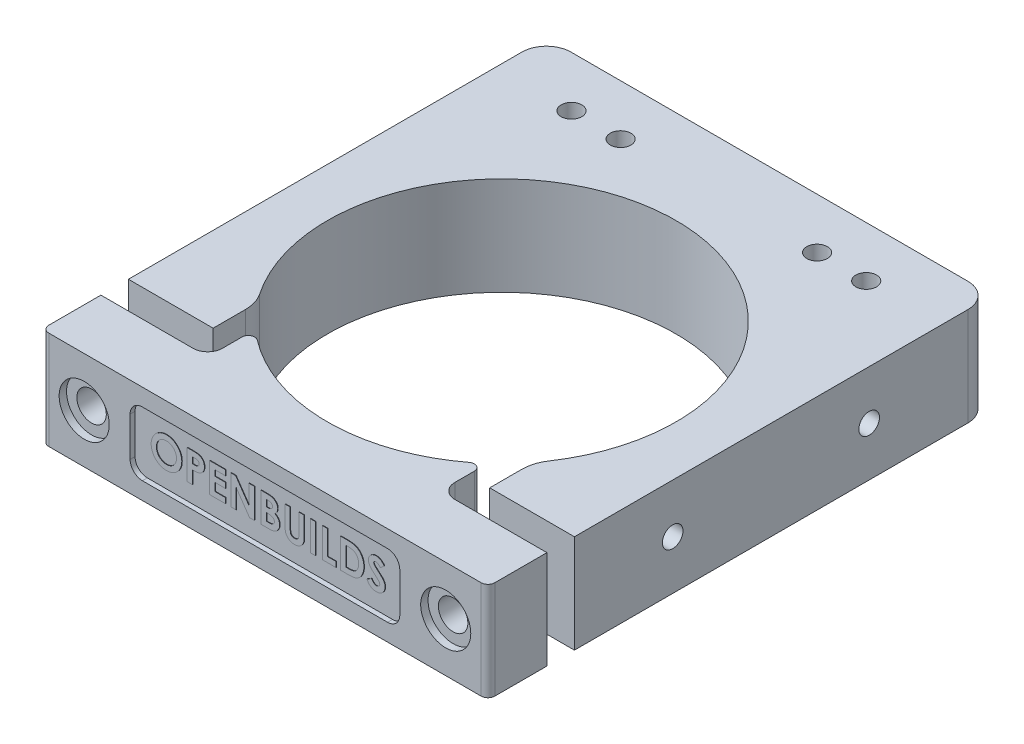
from build123d import *

# Parameters (mm, degrees)
BOSS_EXTRUDE1_DEPTH            = 20
BOSS_EXTRUDE1_2_DEPTH          = 20
SKETCH2_W                      = 2.1
SKETCH2_H                      = 20
M5X0_8_TAPPED_HOLE1_AT_2_COUNT = 2
M5X0_8_TAPPED_HOLE1_AT_2_PITCH = 10
M5X0_8_TAPPED_HOLE1_AT_3_COUNT = 2
M5X0_8_TAPPED_HOLE1_AT_3_PITCH = 50
M5X0_8_TAPPED_HOLE1_AT_4_COUNT = 2
M5X0_8_TAPPED_HOLE1_AT_4_PITCH = 60
HOLE1_AT_2_COUNT               = 2
HOLE1_AT_2_PITCH               = 73.6
M5X0_8_TAPPED_HOLE2_AT_2_COUNT = 2
M5X0_8_TAPPED_HOLE2_AT_2_PITCH = 73.6
M5X0_8_TAPPED_HOLE3_AT_2_COUNT = 2
M5X0_8_TAPPED_HOLE3_AT_2_PITCH = 40
M5X0_8_TAPPED_HOLE4_AT_2_COUNT = 2
M5X0_8_TAPPED_HOLE4_AT_2_PITCH = 20
M5X0_8_TAPPED_HOLE4_AT_3_COUNT = 2
M5X0_8_TAPPED_HOLE4_AT_3_PITCH = 60
M5X0_8_TAPPED_HOLE4_AT_4_COUNT = 2
M5X0_8_TAPPED_HOLE4_AT_4_PITCH = 40
CUT_EXTRUDE1_DEPTH             = 1
SKETCH13_W                     = 1.076923077
SKETCH13_H                     = 6
BOSS_EXTRUDE2_DEPTH            = 0.1


with BuildPart() as part:
    # Sketch1 → Boss-Extrude1 (new body)
    with BuildSketch(Plane(origin=(0, 0, 0), x_dir=(1, 0, 0), z_dir=(0, 1, 0))):
        with BuildLine():
            Line((-45.4, -30.6), (-28.15, -30.6))
            Line((-28.15, -30.6), (-28.15, -24.043242294))
            ThreePointArc((-28.15, -24.043242294), (-28.477651207, -21.850660986), (-29.431976744, -19.849653522))
            ThreePointArc((-29.431976744, -19.849653522), (0, 35.5), (29.431976744, -19.849653522))
            ThreePointArc((29.431976744, -19.849653522), (28.477651207, -21.850660986), (28.15, -24.043242294))
            Line((28.15, -24.043242294), (28.15, -30.6))
            Line((28.15, -30.6), (45.4, -30.6))
            Line((45.4, -30.6), (45.4, 49.5))
            ThreePointArc((45.4, 49.5), (43.935533906, 53.035533906), (40.4, 54.5))
            Line((40.4, 54.5), (-40.4, 54.5))
            ThreePointArc((-40.4, 54.5), (-43.935533906, 53.035533906), (-45.4, 49.5))
            Line((-45.4, 49.5), (-45.4, -30.6))
        make_face()
    extrude(amount=BOSS_EXTRUDE1_DEPTH)

    # Sketch2 → M5x0.8 Tapped Hole1 (revolve, cut)
    with BuildSketch(Plane(origin=(-30, 20, -44.2), x_dir=(0, 0, 1), z_dir=(1, 0, 0))):
        with Locations((1.05, 10)):
            Rectangle(SKETCH2_W, SKETCH2_H)
    m5x0_8_tapped_hole1 = revolve(axis=Axis((-30, 26.35, -44.2), (0, -1, 0)), mode=Mode.SUBTRACT)

    # M5x0.8 Tapped Hole1 at 2: M5x0.8 Tapped Hole1 ×2
    with Locations(*[(i * M5X0_8_TAPPED_HOLE1_AT_2_PITCH, 0, 0) for i in range(1, M5X0_8_TAPPED_HOLE1_AT_2_COUNT)]):
        add(m5x0_8_tapped_hole1, mode=Mode.SUBTRACT)

    # M5x0.8 Tapped Hole1 at 3: M5x0.8 Tapped Hole1 ×2
    with Locations(*[(i * M5X0_8_TAPPED_HOLE1_AT_3_PITCH, 0, 0) for i in range(1, M5X0_8_TAPPED_HOLE1_AT_3_COUNT)]):
        add(m5x0_8_tapped_hole1, mode=Mode.SUBTRACT)

    # M5x0.8 Tapped Hole1 at 4: M5x0.8 Tapped Hole1 ×2
    with Locations(*[(i * M5X0_8_TAPPED_HOLE1_AT_4_PITCH, 0, 0) for i in range(1, M5X0_8_TAPPED_HOLE1_AT_4_COUNT)]):
        add(m5x0_8_tapped_hole1, mode=Mode.SUBTRACT)

    # Sketch6 → M5x0.8 Tapped Hole2 (revolve, cut)
    with BuildSketch(Plane(origin=(36.8, 10, 30.6), x_dir=(0, -1, 0), z_dir=(1, 0, 0))):
        Polygon((0, 0), (0, 14.2618073), (2.1, 13), (2.1, 0), align=None)
    m5x0_8_tapped_hole2 = revolve(axis=Axis((36.8, 10, 36.95), (0, 0, -1)), mode=Mode.SUBTRACT)

    # M5x0.8 Tapped Hole2 at 2: M5x0.8 Tapped Hole2 ×2
    with Locations(*[(-i * M5X0_8_TAPPED_HOLE2_AT_2_PITCH, 0, 0) for i in range(1, M5X0_8_TAPPED_HOLE2_AT_2_COUNT)]):
        add(m5x0_8_tapped_hole2, mode=Mode.SUBTRACT)

    # Sketch8 → M5x0.8 Tapped Hole3 (revolve, cut)
    with BuildSketch(Plane(origin=(45.4, 10, 10.6), x_dir=(0, 0, -1), z_dir=(0, 1, 0))):
        Polygon((0, 0), (0, 10.2618073), (2.1, 9), (2.1, 0), align=None)
    m5x0_8_tapped_hole3 = revolve(axis=Axis((51.75, 10, 10.6), (-1, 0, 0)), mode=Mode.SUBTRACT)

    # M5x0.8 Tapped Hole3 at 2: M5x0.8 Tapped Hole3 ×2
    with Locations(*[(0, 0, -i * M5X0_8_TAPPED_HOLE3_AT_2_PITCH) for i in range(1, M5X0_8_TAPPED_HOLE3_AT_2_COUNT)]):
        add(m5x0_8_tapped_hole3, mode=Mode.SUBTRACT)

    # Mirror1: M5x0.8 Tapped Hole3 across plane
    add(m5x0_8_tapped_hole3.mirror(Plane(origin=(0, 0, 0), x_dir=(0, 0, 1), z_dir=(1, 0, 0))), mode=Mode.SUBTRACT)

    # Mirror1 copy 1 sketch → Mirror1 copy 1 (revolve, cut)
    with BuildSketch(Plane(origin=(-45.4, 10, -29.4), x_dir=(0, 0, -1), z_dir=(0, 1, 0))):
        Polygon((0, 0), (0, -10.2618073), (2.1, -9), (2.1, 0), align=None)
    revolve(axis=Axis((-51.75, 10, -29.4), (-1, 0, 0)), mode=Mode.SUBTRACT)

    # Sketch10 → M5x0.8 Tapped Hole4 (revolve, cut)
    with BuildSketch(Plane(origin=(30, 10, -54.5), x_dir=(0, 1, 0), z_dir=(1, 0, 0))):
        Polygon((0, 0), (0, 8.2618073), (2.1, 7), (2.1, 0), align=None)
    m5x0_8_tapped_hole4 = revolve(axis=Axis((30, 10, -60.85), (0, 0, 1)), mode=Mode.SUBTRACT)

    # M5x0.8 Tapped Hole4 at 2: M5x0.8 Tapped Hole4 ×2
    with Locations(*[(-i * M5X0_8_TAPPED_HOLE4_AT_2_PITCH, 0, 0) for i in range(1, M5X0_8_TAPPED_HOLE4_AT_2_COUNT)]):
        add(m5x0_8_tapped_hole4, mode=Mode.SUBTRACT)

    # M5x0.8 Tapped Hole4 at 3: M5x0.8 Tapped Hole4 ×2
    with Locations(*[(-i * M5X0_8_TAPPED_HOLE4_AT_3_PITCH, 0, 0) for i in range(1, M5X0_8_TAPPED_HOLE4_AT_3_COUNT)]):
        add(m5x0_8_tapped_hole4, mode=Mode.SUBTRACT)

    # M5x0.8 Tapped Hole4 at 4: M5x0.8 Tapped Hole4 ×2
    with Locations(*[(-i * M5X0_8_TAPPED_HOLE4_AT_4_PITCH, 0, 0) for i in range(1, M5X0_8_TAPPED_HOLE4_AT_4_COUNT)]):
        add(m5x0_8_tapped_hole4, mode=Mode.SUBTRACT)


with BuildPart() as body_2:
    # Sketch1 → Boss-Extrude1 2 (new body)
    with BuildSketch(Plane(origin=(0, 0, 0), x_dir=(1, 0, 0), z_dir=(0, 1, 0))):
        with BuildLine():
            Line((-23.65, -29.235551987), (-23.65, -33.2))
            ThreePointArc((-23.65, -33.2), (-24.528679656, -35.321320344), (-26.65, -36.2))
            Line((-26.65, -36.2), (-45.4, -36.2))
            Line((-45.4, -36.2), (-45.4, -46.8))
            ThreePointArc((-45.4, -46.8), (-44.989949494, -47.789949494), (-44, -48.2))
            Line((-44, -48.2), (44, -48.2))
            ThreePointArc((44, -48.2), (44.989949494, -47.789949494), (45.4, -46.8))
            Line((45.4, -46.8), (45.4, -36.2))
            Line((45.4, -36.2), (26.65, -36.2))
            ThreePointArc((26.65, -36.2), (24.528679656, -35.321320344), (23.65, -33.2))
            Line((23.65, -33.2), (23.65, -29.235551987))
            ThreePointArc((23.65, -29.235551987), (22.926021069, -28.070133724), (21.560461957, -28.202774336))
            ThreePointArc((21.560461957, -28.202774336), (0, -35.5), (-21.560461957, -28.202774336))
            ThreePointArc((-21.560461957, -28.202774336), (-22.926021069, -28.070133724), (-23.65, -29.235551987))
        make_face()
    extrude(amount=BOSS_EXTRUDE1_2_DEPTH)

    # Sketch4 → Hole1 (revolve, cut)
    with BuildSketch(Plane(origin=(36.8, 10, 48.2), x_dir=(0, -1, 0), z_dir=(1, 0, 0))):
        Polygon((0, 0), (0, 12), (3, 12), (3, 1.5), (5.1, 1.5), (5.1, 0), align=None)
    hole1 = revolve(axis=Axis((36.8, 10, -61.8), (0, 0, 1)), mode=Mode.SUBTRACT)

    # Hole1 at 2: Hole1 ×2
    with Locations(*[(-i * HOLE1_AT_2_PITCH, 0, 0) for i in range(1, HOLE1_AT_2_COUNT)]):
        add(hole1, mode=Mode.SUBTRACT)

    # Sketch12 → Cut-Extrude1 (cut)
    with BuildSketch(Plane.XY.offset(48.2)):
        with BuildLine():
            Line((-24.95, 16.5), (24.95, 16.5))
            ThreePointArc((24.95, 16.5), (26.717766953, 15.767766953), (27.45, 14))
            Line((27.45, 14), (27.45, 6))
            ThreePointArc((27.45, 6), (26.717766953, 4.232233047), (24.95, 3.5))
            Line((24.95, 3.5), (-24.95, 3.5))
            ThreePointArc((-24.95, 3.5), (-26.717766953, 4.232233047), (-27.45, 6))
            Line((-27.45, 6), (-27.45, 14))
            ThreePointArc((-27.45, 14), (-26.717766953, 15.767766953), (-24.95, 16.5))
        make_face()
    extrude(amount=-CUT_EXTRUDE1_DEPTH, mode=Mode.SUBTRACT)

    # Sketch13 → Boss-Extrude2 (add)
    with BuildSketch(Plane.XY.offset(47.2)):
        with BuildLine():
            add(Edge.make_bspline(
                [(-20.937980769, 13.153846154), (-20.833663416, 13.151145191), (-20.627717333, 13.145812878), (-20.324844963, 13.101363888), (-20.032971434, 13.028940632), (-19.75222873, 12.928267067), (-19.483319798, 12.796616443), (-19.225296106, 12.63772114), (-18.979081884, 12.448582105), (-18.747200137, 12.233611639), (-18.532899583, 11.999840645), (-18.347208027, 11.748144608), (-18.18885708, 11.485045226), (-18.057615392, 11.209837517), (-17.957650418, 10.920615535), (-17.887500861, 10.618853931), (-17.842433246, 10.304638552), (-17.837249777, 10.090700708), (-17.834615385, 9.981971154)],
                knots=[0, 0, 0, 0, 0.000312833, 0.000617603, 0.000916108, 0.001213799, 0.001510526, 0.001812733, 0.0021214, 0.002440363, 0.002760287, 0.00307135, 0.003377038, 0.003680266, 0.003984355, 0.00429309, 0.004608572, 0.004934612, 0.004934612, 0.004934612, 0.004934612], degree=3))
            add(Edge.make_bspline(
                [(-17.834615385, 9.981971154), (-17.837420899, 9.874466731), (-17.842949255, 9.662625816), (-17.885661004, 9.351306056), (-17.956991888, 9.052776947), (-18.055261377, 8.766362762), (-18.184122838, 8.493450793), (-18.339385768, 8.232298534), (-18.525147263, 7.985329542), (-18.734631871, 7.752676349), (-18.965256244, 7.541493654), (-19.209524067, 7.355389269), (-19.466307461, 7.197691436), (-19.735230577, 7.068472389), (-20.016870108, 6.968190245), (-20.31053037, 6.897433906), (-20.616193192, 6.85443385), (-20.824058733, 6.848941605), (-20.929567308, 6.846153846)],
                knots=[0, 0, 0, 0, 0.000322438, 0.000635375, 0.000940602, 0.001242026, 0.001542054, 0.001844445, 0.002151897, 0.002467619, 0.002782372, 0.003088626, 0.003387526, 0.003684812, 0.003982098, 0.004282651, 0.004589633, 0.004906068, 0.004906068, 0.004906068, 0.004906068], degree=3))
            add(Edge.make_bspline(
                [(-20.929567308, 6.846153846), (-21.039916625, 6.848654603), (-21.256737951, 6.853568248), (-21.574056932, 6.900294773), (-21.878075934, 6.970681242), (-22.166241023, 7.07572927), (-22.441486914, 7.207048139), (-22.701791295, 7.3687752), (-22.947066685, 7.560643185), (-23.175906146, 7.777738284), (-23.383235252, 8.015287939), (-23.566243856, 8.266238084), (-23.720615673, 8.528671681), (-23.846356351, 8.802711553), (-23.945485251, 9.08665461), (-24.015409426, 9.382230147), (-24.056715306, 9.688729266), (-24.062468975, 9.896909595), (-24.065384615, 10.002403846)],
                knots=[0, 0, 0, 0, 0.000330843, 0.000650062, 0.000960244, 0.001265535, 0.001568196, 0.001873711, 0.002182895, 0.002500867, 0.002818586, 0.003127518, 0.003431364, 0.00373038, 0.004030668, 0.004332109, 0.004640121, 0.004956555, 0.004956555, 0.004956555, 0.004956555], degree=3))
            add(Edge.make_bspline(
                [(-24.065384615, 10.002403846), (-24.064469519, 10.073374856), (-24.062650915, 10.214418219), (-24.040743905, 10.423437283), (-24.009204109, 10.628376576), (-23.962558248, 10.828419002), (-23.905895448, 11.024975766), (-23.832480788, 11.216217271), (-23.748915036, 11.4041865), (-23.651276323, 11.586663302), (-23.542711516, 11.761968738), (-23.424257644, 11.929275862), (-23.295616859, 12.086561686), (-23.157203555, 12.234859827), (-23.00854074, 12.373195511), (-22.85158392, 12.503527073), (-22.683289048, 12.622392443), (-22.507339569, 12.732694549), (-22.324727447, 12.832438831), (-22.136196078, 12.91733818), (-21.945629581, 12.991479336), (-21.750482245, 13.049994815), (-21.55284542, 13.09765506), (-21.350607758, 13.129173598), (-21.14559636, 13.151080001), (-21.007350204, 13.152921915), (-20.937980769, 13.153846154)],
                knots=[0, 0, 0, 0, 0.000212825, 0.000422956, 0.000629844, 0.000834524, 0.001038755, 0.001243015, 0.001448526, 0.00165554, 0.001863337, 0.002066771, 0.00227007, 0.002472458, 0.002674845, 0.002878907, 0.003084017, 0.00329245, 0.00350166, 0.003707666, 0.003912354, 0.004114627, 0.004318409, 0.004521736, 0.004728278, 0.004936298, 0.004936298, 0.004936298, 0.004936298], degree=3))
        make_face()
        with BuildLine():
            add(Edge.make_bspline(
                [(-20.954807692, 12.076923077), (-21.025013257, 12.075039304), (-21.163570949, 12.07132149), (-21.366809849, 12.042996776), (-21.56192637, 11.997758988), (-21.747838905, 11.932232606), (-21.925353215, 11.848834151), (-22.094783976, 11.747855029), (-22.253784924, 11.625824195), (-22.404476183, 11.489292941), (-22.540600939, 11.337165746), (-22.660871455, 11.174135586), (-22.761518505, 11.000474717), (-22.84581104, 10.817796407), (-22.909264637, 10.624046488), (-22.954460731, 10.420742624), (-22.983022976, 10.207534511), (-22.986623282, 10.062190819), (-22.988461538, 9.987980769)],
                knots=[0, 0, 0, 0, 0.000210556, 0.000415554, 0.00061438, 0.000810526, 0.001005704, 0.001201938, 0.001400979, 0.001606015, 0.001811136, 0.00201235, 0.002212721, 0.002412262, 0.002614846, 0.002823043, 0.00303638, 0.003258943, 0.003258943, 0.003258943, 0.003258943], degree=3))
            add(Edge.make_bspline(
                [(-22.988461538, 9.987980769), (-22.986024292, 9.905739341), (-22.981247692, 9.744559769), (-22.947638953, 9.509435351), (-22.890137748, 9.287383675), (-22.807107124, 9.079490762), (-22.704127368, 8.883448116), (-22.576242855, 8.70165852), (-22.425524709, 8.533033501), (-22.30941267, 8.434583191), (-22.250480769, 8.384615385)],
                knots=[0, 0, 0, 0, 0.000246687, 0.000483466, 0.000710858, 0.000933159, 0.001153606, 0.001373676, 0.001598362, 0.001829931, 0.001829931, 0.001829931, 0.001829931], degree=3))
            add(Edge.make_bspline(
                [(-22.250480769, 8.384615385), (-22.202204292, 8.347701088), (-22.106739014, 8.274704181), (-21.954355646, 8.18114367), (-21.797430783, 8.100952979), (-21.63478023, 8.036159849), (-21.466747496, 7.985194662), (-21.293355625, 7.949504579), (-21.114850296, 7.927105966), (-20.994136627, 7.924428907), (-20.933173077, 7.923076923)],
                knots=[0, 0, 0, 0, 0.000182217, 0.000360329, 0.000535563, 0.000710322, 0.000884849, 0.001061642, 0.001240837, 0.001423672, 0.001423672, 0.001423672, 0.001423672], degree=3))
            add(Edge.make_bspline(
                [(-20.933173077, 7.923076923), (-20.864174698, 7.924976668), (-20.728418218, 7.928714477), (-20.52896272, 7.956690498), (-20.337878295, 8.004036027), (-20.153978675, 8.068987589), (-19.977794143, 8.153433183), (-19.810185762, 8.257544361), (-19.650859669, 8.38004277), (-19.500360389, 8.518366979), (-19.362796933, 8.67109345), (-19.242777397, 8.834993196), (-19.138930274, 9.006455017), (-19.056390603, 9.187905695), (-18.990430098, 9.377632419), (-18.945777962, 9.57647545), (-18.916974431, 9.78361508), (-18.91337311, 9.924580918), (-18.911538462, 9.996394231)],
                knots=[0, 0, 0, 0, 0.000206954, 0.000407189, 0.000602793, 0.000796671, 0.000991279, 0.001187737, 0.001387506, 0.001593355, 0.001800173, 0.002003066, 0.00220198, 0.002400429, 0.00259998, 0.002803489, 0.003010869, 0.003226228, 0.003226228, 0.003226228, 0.003226228], degree=3))
            add(Edge.make_bspline(
                [(-18.911538462, 9.996394231), (-18.913436589, 10.067794597), (-18.917172764, 10.20833533), (-18.945198025, 10.414942405), (-18.9922433, 10.612907602), (-19.057389905, 10.802554218), (-19.14057867, 10.984068178), (-19.243450016, 11.156811172), (-19.365642982, 11.320616198), (-19.504345304, 11.474366989), (-19.655314257, 11.615654117), (-19.817394512, 11.738265661), (-19.986050882, 11.844811194), (-20.165153167, 11.928274662), (-20.351037085, 11.99476983), (-20.544836909, 12.043737826), (-20.747286667, 12.071122508), (-20.885017424, 12.074972319), (-20.954807692, 12.076923077)],
                knots=[0, 0, 0, 0, 0.000214158, 0.000421538, 0.00062415, 0.000823702, 0.00102215, 0.001222096, 0.001425704, 0.00163422, 0.001842583, 0.002044992, 0.002243105, 0.002439883, 0.00263643, 0.002834656, 0.003038462, 0.003247818, 0.003247818, 0.003247818, 0.003247818], degree=3))
        make_face(mode=Mode.SUBTRACT)
        with BuildLine():
            Line((-16.757692308, 13), (-15.555769231, 13))
            add(Edge.make_bspline(
                [(-15.555769231, 13), (-15.477237136, 12.999648474), (-15.325732264, 12.998970306), (-15.107249774, 12.990746616), (-14.90568898, 12.976009263), (-14.721096189, 12.957796225), (-14.553547302, 12.932262255), (-14.402832497, 12.902989558), (-14.268920498, 12.867326893), (-14.150301247, 12.824995803), (-14.0438443, 12.775089103), (-13.943101694, 12.721934905), (-13.850350221, 12.658497244), (-13.760908434, 12.591613162), (-13.679889876, 12.514893249), (-13.602240122, 12.433443325), (-13.531247852, 12.344033154), (-13.466584114, 12.247745023), (-13.40792414, 12.146357923), (-13.356674862, 12.039690606), (-13.315104318, 11.92757428), (-13.280231801, 11.810734212), (-13.252221855, 11.689175493), (-13.233577544, 11.562150526), (-13.22091339, 11.430546248), (-13.219795953, 11.340976294), (-13.219230769, 11.295673077)],
                knots=[0, 0, 0, 0, 0.000235589, 0.000454501, 0.00065574, 0.000841832, 0.001010795, 0.001164011, 0.001302211, 0.001426155, 0.001541245, 0.001654723, 0.001767397, 0.00187798, 0.001989397, 0.002101634, 0.002215385, 0.002331394, 0.002449317, 0.002566516, 0.002685948, 0.002807634, 0.002932136, 0.003059795, 0.003192551, 0.003328417, 0.003328417, 0.003328417, 0.003328417], degree=3))
            add(Edge.make_bspline(
                [(-13.219230769, 11.295673077), (-13.220048519, 11.245555207), (-13.221655499, 11.147067433), (-13.237409075, 11.00269644), (-13.264321161, 10.865051769), (-13.29949385, 10.732972639), (-13.348539663, 10.608632043), (-13.404572201, 10.489063176), (-13.473509997, 10.377618384), (-13.552282448, 10.272903626), (-13.638310952, 10.174067521), (-13.733637822, 10.083963775), (-13.836446085, 10.001978153), (-13.946140622, 9.927251441), (-14.06313326, 9.859934378), (-14.187339582, 9.799396612), (-14.319607739, 9.747574329), (-14.411715304, 9.720471694), (-14.458413462, 9.706730769)],
                knots=[0, 0, 0, 0, 0.000150317, 0.000295392, 0.000434939, 0.00057082, 0.000704747, 0.000835381, 0.000966485, 0.001097014, 0.001228172, 0.001359099, 0.001489932, 0.00162228, 0.001756901, 0.001894515, 0.002036469, 0.002182452, 0.002182452, 0.002182452, 0.002182452], degree=3))
            add(Edge.make_bspline(
                [(-14.458413462, 9.706730769), (-14.489171555, 9.699078106), (-14.555803489, 9.682499973), (-14.666061038, 9.665669007), (-14.793121287, 9.650193968), (-14.937395105, 9.636895046), (-15.098965669, 9.627854878), (-15.277676537, 9.620794909), (-15.473608697, 9.615661582), (-15.609852173, 9.615479429), (-15.680769231, 9.615384615)],
                knots=[0, 0, 0, 0, 9.5043e-05, 0.000205894, 0.000334253, 0.000479088, 0.000640432, 0.000819664, 0.001015637, 0.00122838, 0.00122838, 0.00122838, 0.00122838], degree=3))
            Line((-15.680769231, 9.615384615), (-15.680769231, 7))
            Line((-15.680769231, 7), (-16.757692308, 7))
            Line((-16.757692308, 7), (-16.757692308, 13))
        make_face()
        with BuildLine():
            Line((-15.680769231, 10.692307692), (-15.299759615, 10.692307692))
            add(Edge.make_bspline(
                [(-15.299759615, 10.692307692), (-15.230428901, 10.692747303), (-15.102859355, 10.693556193), (-14.928644406, 10.705253211), (-14.788641921, 10.723116921), (-14.678037358, 10.748737613), (-14.59070458, 10.787620405), (-14.515385526, 10.832600473), (-14.45078245, 10.889476535), (-14.394845696, 10.954467167), (-14.350125946, 11.02914466), (-14.319115129, 11.112293038), (-14.298971112, 11.202165262), (-14.297110625, 11.264710381), (-14.296153846, 11.296875)],
                knots=[0, 0, 0, 0, 0.000207964, 0.000382657, 0.0005234, 0.000631259, 0.000721691, 0.000809093, 0.000893442, 0.000978702, 0.001065483, 0.001152984, 0.001243981, 0.001340323, 0.001340323, 0.001340323, 0.001340323], degree=3))
            add(Edge.make_bspline(
                [(-14.296153846, 11.296875), (-14.297100783, 11.324976808), (-14.298938069, 11.379501073), (-14.312435272, 11.458193112), (-14.33394593, 11.531550325), (-14.365114046, 11.598806594), (-14.405407041, 11.65984764), (-14.454532355, 11.714649416), (-14.511859614, 11.764385549), (-14.55611961, 11.790711645), (-14.578605769, 11.804086538)],
                knots=[0, 0, 0, 0, 8.4272e-05, 0.000163508, 0.000238798, 0.000313007, 0.000385012, 0.000457377, 0.000533251, 0.000611607, 0.000611607, 0.000611607, 0.000611607], degree=3))
            add(Edge.make_bspline(
                [(-14.578605769, 11.804086538), (-14.597652844, 11.81371919), (-14.637979404, 11.834113488), (-14.706659445, 11.85782335), (-14.785915164, 11.877825231), (-14.876281626, 11.894426599), (-14.977398333, 11.907310984), (-15.089247245, 11.917164316), (-15.211992957, 11.921126725), (-15.297355256, 11.922408927), (-15.341826923, 11.923076923)],
                knots=[0, 0, 0, 0, 6.3973e-05, 0.000135445, 0.000217361, 0.000309062, 0.000410886, 0.000523078, 0.000645768, 0.000779203, 0.000779203, 0.000779203, 0.000779203], degree=3))
            Line((-15.341826923, 11.923076923), (-15.680769231, 11.923076923))
            Line((-15.680769231, 11.923076923), (-15.680769231, 10.692307692))
        make_face(mode=Mode.SUBTRACT)
        Polygon((-12.142307692, 13), (-8.911538462, 13), (-8.911538462, 11.923076923), (-11.065384615, 11.923076923), (-11.065384615, 10.769230769), (-8.911538462, 10.769230769), (-8.911538462, 9.692307692), (-11.065384615, 9.692307692), (-11.065384615, 8.076923077), (-8.911538462, 8.076923077), (-8.911538462, 7), (-12.142307692, 7), align=None)
        Polygon((-7.834615385, 13), (-6.864663462, 13), (-4.142307692, 9.051682692), (-4.142307692, 13), (-3.065384615, 13), (-3.065384615, 7), (-4.042548077, 7), (-6.757692308, 10.936298077), (-6.757692308, 7), (-7.834615385, 7), align=None)
        with BuildLine():
            Line((-1.680769231, 7), (-1.680769231, 13))
            Line((-1.680769231, 13), (-0.719230769, 13))
            add(Edge.make_bspline(
                [(-0.719230769, 13), (-0.651917065, 13.000007682), (-0.521666323, 13.000022547), (-0.333748494, 12.99342349), (-0.159470578, 12.98488687), (0.000612805, 12.975336378), (0.146774129, 12.958878971), (0.278791131, 12.941534662), (0.396927582, 12.920618495), (0.46996493, 12.901856045), (0.504326923, 12.893028846)],
                knots=[0, 0, 0, 0, 0.000201927, 0.000390724, 0.000564006, 0.000725426, 0.000871696, 0.001005131, 0.00112489, 0.001231292, 0.001231292, 0.001231292, 0.001231292], degree=3))
            add(Edge.make_bspline(
                [(0.504326923, 12.893028846), (0.549447709, 12.880577925), (0.637989176, 12.856145221), (0.764808812, 12.806802319), (0.885114927, 12.751954185), (0.998760631, 12.689382723), (1.105048094, 12.618332519), (1.203573386, 12.538239698), (1.296461456, 12.452319182), (1.380414059, 12.35817639), (1.456293381, 12.258697092), (1.522218906, 12.153907354), (1.579499738, 12.045409478), (1.625339408, 11.931838092), (1.659878737, 11.813716223), (1.685140659, 11.691548268), (1.701513805, 11.56494766), (1.703060852, 11.478817128), (1.703846154, 11.435096154)],
                knots=[0, 0, 0, 0, 0.000140337, 0.000275386, 0.000407685, 0.000536801, 0.000664143, 0.000790659, 0.000917364, 0.001043331, 0.001168573, 0.001292284, 0.001414319, 0.001536182, 0.00165902, 0.00178301, 0.001910176, 0.002041273, 0.002041273, 0.002041273, 0.002041273], degree=3))
            add(Edge.make_bspline(
                [(1.703846154, 11.435096154), (1.701792824, 11.378926178), (1.697751097, 11.268362483), (1.671932267, 11.105964419), (1.623517938, 10.952474905), (1.560168966, 10.80506519), (1.474034169, 10.664285111), (1.364659636, 10.530201607), (1.233816876, 10.398686045), (1.133453257, 10.319851336), (1.08125, 10.278846154)],
                knots=[0, 0, 0, 0, 0.000168544, 0.000331758, 0.000491437, 0.000650209, 0.000812023, 0.000984716, 0.001168291, 0.001367278, 0.001367278, 0.001367278, 0.001367278], degree=3))
            add(Edge.make_bspline(
                [(1.08125, 10.278846154), (1.123553015, 10.257250832), (1.206497523, 10.21490838), (1.324254357, 10.145310028), (1.433284331, 10.071283355), (1.534076302, 9.994317806), (1.624516044, 9.911150699), (1.708337965, 9.826574239), (1.781406727, 9.735742545), (1.846747016, 9.641893033), (1.903539734, 9.543666749), (1.952999928, 9.441229577), (1.99477718, 9.334231568), (2.030155238, 9.223217256), (2.056540202, 9.107804804), (2.07374376, 8.987952935), (2.08691588, 8.864070405), (2.087940547, 8.779684719), (2.088461538, 8.736778846)],
                knots=[0, 0, 0, 0, 0.000142467, 0.000279339, 0.000410017, 0.000537676, 0.000659355, 0.000778352, 0.000894547, 0.001008572, 0.00112113, 0.001234557, 0.001349503, 0.001465443, 0.001583819, 0.001704167, 0.001828548, 0.001957204, 0.001957204, 0.001957204, 0.001957204], degree=3))
            add(Edge.make_bspline(
                [(2.088461538, 8.736778846), (2.085080651, 8.654831082), (2.078408483, 8.493107499), (2.029624848, 8.255660137), (1.945049524, 8.030538501), (1.831482305, 7.818637321), (1.69154564, 7.626090788), (1.530658605, 7.457421697), (1.350440963, 7.314647056), (1.184168407, 7.21828525), (1.040355739, 7.153617467), (0.921238393, 7.113635765), (0.793308889, 7.076596777), (0.654223865, 7.050587235), (0.506504742, 7.026780442), (0.348711251, 7.012081635), (0.181138304, 7.002120616), (0.06604196, 7.000721163), (0.006730769, 7)],
                knots=[0, 0, 0, 0, 0.000245769, 0.000485024, 0.000723469, 0.000964915, 0.001204125, 0.00143535, 0.001662107, 0.001891548, 0.002009924, 0.0021346, 0.002268165, 0.002409123, 0.002558713, 0.002716938, 0.002884282, 0.003062203, 0.003062203, 0.003062203, 0.003062203], degree=3))
            Line((0.006730769, 7), (-1.680769231, 7))
        make_face()
        with BuildLine():
            Line((-0.603846154, 11.923076923), (-0.603846154, 10.615384615))
            Line((-0.603846154, 10.615384615), (-0.317788462, 10.615384615))
            add(Edge.make_bspline(
                [(-0.317788462, 10.615384615), (-0.278910651, 10.615723645), (-0.203859391, 10.61637812), (-0.095455806, 10.624807536), (0.005342021, 10.639188643), (0.098151786, 10.659253904), (0.183838046, 10.684733861), (0.261853413, 10.715391736), (0.331854866, 10.752797677), (0.413180364, 10.808515476), (0.49914728, 10.890506711), (0.57482299, 11.008960039), (0.619395477, 11.145180915), (0.62435965, 11.241254424), (0.626923077, 11.290865385)],
                knots=[0, 0, 0, 0, 0.000116611, 0.000225111, 0.000325908, 0.000421859, 0.000509698, 0.000593841, 0.000672885, 0.00074723, 0.000889184, 0.001025892, 0.001165004, 0.001313542, 0.001313542, 0.001313542, 0.001313542], degree=3))
            add(Edge.make_bspline(
                [(0.626923077, 11.290865385), (0.624871866, 11.337334292), (0.620905933, 11.427180057), (0.576027169, 11.553331513), (0.506321576, 11.665127521), (0.424024326, 11.741642746), (0.346525473, 11.793900389), (0.280166199, 11.828309821), (0.207331914, 11.859112794), (0.126612622, 11.882665497), (0.038469277, 11.900338616), (-0.056669962, 11.913317406), (-0.158969242, 11.922151322), (-0.229627572, 11.922761771), (-0.266105769, 11.923076923)],
                knots=[0, 0, 0, 0, 0.000138852, 0.000268465, 0.000396508, 0.000530833, 0.000601838, 0.00067657, 0.000754695, 0.000838735, 0.000928309, 0.001024177, 0.001126686, 0.001236088, 0.001236088, 0.001236088, 0.001236088], degree=3))
            Line((-0.266105769, 11.923076923), (-0.603846154, 11.923076923))
        make_face(mode=Mode.SUBTRACT)
        with BuildLine():
            Line((-0.603846154, 9.615384615), (-0.603846154, 8.076923077))
            Line((-0.603846154, 8.076923077), (-0.29375, 8.076923077))
            add(Edge.make_bspline(
                [(-0.29375, 8.076923077), (-0.232443596, 8.077273318), (-0.114574383, 8.077946701), (0.054273055, 8.086082762), (0.207797589, 8.100746578), (0.345592435, 8.119053172), (0.467868653, 8.143855743), (0.574212919, 8.175389034), (0.666083609, 8.210081146), (0.74292986, 8.252930024), (0.805708845, 8.302795491), (0.862360296, 8.353759197), (0.90855036, 8.412550647), (0.9450968, 8.476646086), (0.97672768, 8.544453338), (0.995805193, 8.618620251), (1.010330142, 8.696948697), (1.011129488, 8.751126789), (1.011538462, 8.778846154)],
                knots=[0, 0, 0, 0, 0.00018391, 0.00035359, 0.000506914, 0.000646466, 0.000770457, 0.000880746, 0.000978951, 0.001064525, 0.001143377, 0.00121906, 0.001292642, 0.001366441, 0.001440151, 0.001516262, 0.001595498, 0.001678509, 0.001678509, 0.001678509, 0.001678509], degree=3))
            add(Edge.make_bspline(
                [(1.011538462, 8.778846154), (1.010636558, 8.810543684), (1.008879894, 8.872281944), (0.994533191, 8.962519001), (0.968460545, 9.046761281), (0.935620776, 9.127162973), (0.889922492, 9.200845416), (0.835611643, 9.270358479), (0.769990273, 9.333348237), (0.696195214, 9.393624545), (0.610120584, 9.446399718), (0.511725999, 9.492191529), (0.400476927, 9.530435163), (0.276028761, 9.56088477), (0.138927072, 9.58672693), (-0.011828831, 9.602157552), (-0.1749834, 9.613633984), (-0.288117434, 9.614787812), (-0.346634615, 9.615384615)],
                knots=[0, 0, 0, 0, 9.5074e-05, 0.000185178, 0.000273017, 0.000359187, 0.000444938, 0.000532224, 0.000623166, 0.000717208, 0.000817603, 0.00092514, 0.001042215, 0.001169896, 0.001309221, 0.001460401, 0.00162422, 0.001799737, 0.001799737, 0.001799737, 0.001799737], degree=3))
            Line((-0.346634615, 9.615384615), (-0.603846154, 9.615384615))
        make_face(mode=Mode.SUBTRACT)
        with BuildLine():
            Line((3.165384615, 13), (4.242307692, 13))
            Line((4.242307692, 13), (4.242307692, 9.096153846))
            add(Edge.make_bspline(
                [(4.242307692, 9.096153846), (4.24236625, 9.055680462), (4.242479354, 8.97750654), (4.248141385, 8.865352556), (4.253322534, 8.762259562), (4.262670797, 8.668340422), (4.276481386, 8.583554963), (4.289854543, 8.507358552), (4.307953788, 8.441115399), (4.335154059, 8.365713348), (4.377060749, 8.280995026), (4.445533955, 8.192699646), (4.524546176, 8.112117297), (4.619246875, 8.045043603), (4.725682085, 7.99078703), (4.843266992, 7.950588914), (4.971835844, 7.928244098), (5.060734152, 7.924832753), (5.106490385, 7.923076923)],
                knots=[0, 0, 0, 0, 0.0001214, 0.000234483, 0.000336823, 0.000431065, 0.00051742, 0.000594502, 0.000663022, 0.000723095, 0.000834899, 0.000944755, 0.00105694, 0.00117235, 0.001291146, 0.001414295, 0.001543729, 0.001681006, 0.001681006, 0.001681006, 0.001681006], degree=3))
            add(Edge.make_bspline(
                [(5.106490385, 7.923076923), (5.155100735, 7.924495408), (5.249882688, 7.927261214), (5.386211438, 7.954410594), (5.512520798, 7.997641704), (5.626136368, 8.059343515), (5.726945083, 8.13330395), (5.812277547, 8.217642023), (5.879621615, 8.312525945), (5.923513973, 8.40006359), (5.94815737, 8.480634368), (5.966628824, 8.552621301), (5.980170443, 8.637558757), (5.992455845, 8.734120253), (5.999838425, 8.843305982), (6.00784363, 8.964237856), (6.010777612, 9.097743325), (6.011277687, 9.190705688), (6.011538462, 9.239182692)],
                knots=[0, 0, 0, 0, 0.000145676, 0.000284043, 0.000415185, 0.000544781, 0.000670266, 0.00078925, 0.000902983, 0.001018016, 0.001081114, 0.001155449, 0.001240811, 0.001338906, 0.001447406, 0.001569014, 0.001702476, 0.001847914, 0.001847914, 0.001847914, 0.001847914], degree=3))
            Line((6.011538462, 9.239182692), (6.011538462, 13))
            Line((6.011538462, 13), (7.088461538, 13))
            Line((7.088461538, 13), (7.088461538, 9.420673077))
            add(Edge.make_bspline(
                [(7.088461538, 9.420673077), (7.088311988, 9.348156085), (7.088024417, 9.208712981), (7.083608198, 9.008323427), (7.074206866, 8.825299714), (7.066310831, 8.659588362), (7.0510293, 8.511412612), (7.03510953, 8.380139711), (7.014818413, 8.26623486), (6.98462645, 8.136568031), (6.932524062, 7.987261425), (6.848528181, 7.81534134), (6.741900847, 7.647021164), (6.615872666, 7.484152534), (6.473575322, 7.332852825), (6.318163852, 7.200031265), (6.152107356, 7.087678548), (5.973670665, 6.998541833), (5.783005636, 6.929021915), (5.578225781, 6.882308031), (5.359470745, 6.850747546), (5.208372507, 6.847715772), (5.130528846, 6.846153846)],
                knots=[0, 0, 0, 0, 0.000217551, 0.00041833, 0.000601216, 0.00076736, 0.000915898, 0.001047984, 0.001163981, 0.001262809, 0.001447158, 0.001636914, 0.001835664, 0.002043861, 0.002253867, 0.002457631, 0.002655978, 0.002853785, 0.003054538, 0.003263275, 0.003482889, 0.00371626, 0.00371626, 0.00371626, 0.00371626], degree=3))
            add(Edge.make_bspline(
                [(5.130528846, 6.846153846), (5.078807969, 6.847025016), (4.976763741, 6.848743816), (4.826689801, 6.863899145), (4.681613858, 6.886232401), (4.541808508, 6.918814321), (4.406788513, 6.960904076), (4.276589746, 7.012713634), (4.151696055, 7.073954007), (4.032806329, 7.144061916), (3.920066871, 7.219871551), (3.817028826, 7.303909723), (3.720146413, 7.389961491), (3.632218524, 7.481648279), (3.552584743, 7.578007533), (3.481409075, 7.679257633), (3.418797264, 7.785389587), (3.363174345, 7.898316417), (3.315566554, 8.023777785), (3.275431398, 8.166236405), (3.240368382, 8.327925172), (3.214311617, 8.509208364), (3.190688401, 8.709488491), (3.175736207, 8.929287313), (3.167914042, 9.168611136), (3.166249062, 9.334529381), (3.165384615, 9.420673077)],
                knots=[0, 0, 0, 0, 0.000155123, 0.000306054, 0.000452081, 0.000595231, 0.000736266, 0.000875985, 0.001015205, 0.001153113, 0.001289794, 0.001422317, 0.001551678, 0.001678337, 0.00180299, 0.001926368, 0.002049223, 0.002172319, 0.002303571, 0.002451167, 0.002615954, 0.002799537, 0.003000359, 0.003220866, 0.003460196, 0.003718635, 0.003718635, 0.003718635, 0.003718635], degree=3))
            Line((3.165384615, 9.420673077), (3.165384615, 13))
        make_face()
        with Locations((8.857692308, 10)):
            Rectangle(SKETCH13_W, SKETCH13_H)
        Polygon((10.780769231, 13), (11.857692308, 13), (11.857692308, 8.076923077), (13.55, 8.076923077), (13.55, 7), (10.780769231, 7), align=None)
        with BuildLine():
            Line((14.473076923, 13), (15.830048077, 13))
            add(Edge.make_bspline(
                [(15.830048077, 13), (15.935839586, 12.999260481), (16.14033577, 12.997830983), (16.436610284, 12.981723975), (16.71210788, 12.956952539), (16.96700615, 12.922874941), (17.200782511, 12.877780947), (17.413135513, 12.821219369), (17.604777864, 12.755928437), (17.777810882, 12.679100407), (17.935773384, 12.589526553), (18.085763822, 12.489748472), (18.227487692, 12.376111), (18.362933865, 12.250806431), (18.490354378, 12.111542356), (18.611871241, 11.960625492), (18.724509169, 11.795867338), (18.831672962, 11.621218273), (18.928588354, 11.435938152), (19.01312158, 11.241604041), (19.083935576, 11.039466552), (19.141475614, 10.829310259), (19.187341666, 10.611832817), (19.219433218, 10.386595378), (19.239272535, 10.153806472), (19.241285068, 9.996034), (19.242307692, 9.915865385)],
                knots=[0, 0, 0, 0, 0.000317344, 0.00061343, 0.000889825, 0.001147006, 0.00138461, 0.001603561, 0.001805777, 0.001991396, 0.002170595, 0.00234994, 0.002531267, 0.002714968, 0.002902949, 0.00309704, 0.003295747, 0.003501262, 0.003711464, 0.003922473, 0.004136486, 0.004353432, 0.004575723, 0.004802813, 0.00503558, 0.00527604, 0.00527604, 0.00527604, 0.00527604], degree=3))
            add(Edge.make_bspline(
                [(19.242307692, 9.915865385), (19.23962991, 9.80274225), (19.234358538, 9.580052736), (19.189955446, 9.253258441), (19.118140612, 8.939993515), (19.017162432, 8.642708439), (18.89197652, 8.364050578), (18.742427931, 8.108933949), (18.570709394, 7.878727887), (18.37882144, 7.674578631), (18.171053521, 7.499109578), (17.955140756, 7.348833176), (17.728979762, 7.230327692), (17.52970032, 7.155177495), (17.356900181, 7.108440574), (17.205183529, 7.080818603), (17.032848893, 7.05548759), (16.838289401, 7.035912329), (16.622358544, 7.018456006), (16.384195619, 7.008970919), (16.12457173, 7.00109022), (15.944238391, 7.000372929), (15.850480769, 7)],
                knots=[0, 0, 0, 0, 0.000339249, 0.000667832, 0.000987374, 0.001302085, 0.00160816, 0.001902317, 0.002187414, 0.002468005, 0.002740866, 0.003001907, 0.003255661, 0.003504796, 0.003639202, 0.003792186, 0.003967094, 0.004161679, 0.004378679, 0.004616905, 0.004876621, 0.005157881, 0.005157881, 0.005157881, 0.005157881], degree=3))
            Line((15.850480769, 7), (14.473076923, 7))
            Line((14.473076923, 7), (14.473076923, 13))
        make_face()
        with BuildLine():
            Line((15.55, 11.923076923), (15.55, 8.076923077))
            Line((15.55, 8.076923077), (16.1125, 8.076923077))
            add(Edge.make_bspline(
                [(16.1125, 8.076923077), (16.179428861, 8.077045718), (16.308155342, 8.077281599), (16.494007243, 8.088516776), (16.665873126, 8.099793797), (16.823279886, 8.121197959), (16.96737308, 8.145040689), (17.096173246, 8.178221112), (17.212335513, 8.213074336), (17.314440983, 8.25744681), (17.407961275, 8.307390983), (17.494550382, 8.365906372), (17.578133114, 8.430885504), (17.657146823, 8.504239508), (17.731890558, 8.58499704), (17.801922087, 8.673574207), (17.868176147, 8.769700758), (17.92895212, 8.873884937), (17.984489529, 8.985026536), (18.033757435, 9.102048987), (18.074607798, 9.225926835), (18.10856012, 9.355500433), (18.132822903, 9.491897868), (18.152895729, 9.634108862), (18.163243855, 9.782696844), (18.164664071, 9.883801073), (18.165384615, 9.935096154)],
                knots=[0, 0, 0, 0, 0.000200736, 0.000386081, 0.000558464, 0.000717236, 0.000862475, 0.000996278, 0.001116019, 0.001225861, 0.001329652, 0.001433658, 0.001538969, 0.001646989, 0.001756706, 0.001868769, 0.001985455, 0.002106664, 0.002230293, 0.002357975, 0.002487202, 0.002621302, 0.002759444, 0.002902569, 0.003052, 0.003205888, 0.003205888, 0.003205888, 0.003205888], degree=3))
            add(Edge.make_bspline(
                [(18.165384615, 9.935096154), (18.163949536, 10.013701017), (18.161151241, 10.166974409), (18.134165094, 10.390220451), (18.090236794, 10.600440043), (18.027555344, 10.796853004), (17.948543432, 10.980011357), (17.849641606, 11.148363364), (17.735106221, 11.304737106), (17.644534762, 11.396470961), (17.599278846, 11.442307692)],
                knots=[0, 0, 0, 0, 0.000235727, 0.00045965, 0.00067346, 0.000879101, 0.001077171, 0.001270535, 0.001463806, 0.001656822, 0.001656822, 0.001656822, 0.001656822], degree=3))
            add(Edge.make_bspline(
                [(17.599278846, 11.442307692), (17.554652228, 11.481366784), (17.463507412, 11.561140557), (17.303487068, 11.656729938), (17.127152937, 11.740714578), (16.930471022, 11.807305032), (16.715342167, 11.859967601), (16.480485059, 11.896287687), (16.22715741, 11.91962659), (16.051657918, 11.921902172), (15.961057692, 11.923076923)],
                knots=[0, 0, 0, 0, 0.000177592, 0.000362712, 0.000556803, 0.000762819, 0.000984368, 0.001220499, 0.001475131, 0.001746862, 0.001746862, 0.001746862, 0.001746862], degree=3))
            Line((15.961057692, 11.923076923), (15.55, 11.923076923))
        make_face(mode=Mode.SUBTRACT)
        with BuildLine():
            Line((23.396153846, 12.198317308), (22.590865385, 11.461538462))
            add(Edge.make_bspline(
                [(22.590865385, 11.461538462), (22.55637028, 11.510197393), (22.490144489, 11.603615755), (22.382799391, 11.728705144), (22.27593901, 11.835415702), (22.168573351, 11.923301642), (22.059750765, 11.99182899), (21.949660153, 12.04034711), (21.838925649, 12.071190539), (21.764529155, 12.075031288), (21.727884615, 12.076923077)],
                knots=[0, 0, 0, 0, 0.000178856, 0.00034338, 0.000493812, 0.000631405, 0.000758809, 0.000878284, 0.000991399, 0.001101195, 0.001101195, 0.001101195, 0.001101195], degree=3))
            add(Edge.make_bspline(
                [(21.727884615, 12.076923077), (21.69370364, 12.075724353), (21.627709156, 12.073409931), (21.533629123, 12.05040475), (21.45010353, 12.010701186), (21.377213894, 11.958785436), (21.319474548, 11.896238993), (21.273374158, 11.830643856), (21.247415765, 11.75824166), (21.243999129, 11.708512911), (21.242307692, 11.683894231)],
                knots=[0, 0, 0, 0, 0.000102418, 0.000197742, 0.00028807, 0.00037847, 0.000464347, 0.000542351, 0.000617623, 0.000691421, 0.000691421, 0.000691421, 0.000691421], degree=3))
            add(Edge.make_bspline(
                [(21.242307692, 11.683894231), (21.24336763, 11.658920538), (21.245502198, 11.608626991), (21.266119216, 11.534915534), (21.297194949, 11.46289086), (21.326889081, 11.419046014), (21.342067308, 11.396634615)],
                knots=[0, 0, 0, 0, 7.4761e-05, 0.000150559, 0.000228052, 0.000309082, 0.000309082, 0.000309082, 0.000309082], degree=3))
            add(Edge.make_bspline(
                [(21.342067308, 11.396634615), (21.355865958, 11.37921447), (21.387628628, 11.339115595), (21.448193535, 11.275605228), (21.524250339, 11.197799469), (21.618725865, 11.10837383), (21.727698175, 11.004112216), (21.856218275, 10.889113191), (22.000586798, 10.759815367), (22.103200599, 10.669777045), (22.156971154, 10.622596154)],
                knots=[0, 0, 0, 0, 6.6639e-05, 0.000153394, 0.000263033, 0.000393091, 0.000543581, 0.000715469, 0.000910406, 0.001125009, 0.001125009, 0.001125009, 0.001125009], degree=3))
            add(Edge.make_bspline(
                [(22.156971154, 10.622596154), (22.207442555, 10.578915702), (22.303226788, 10.49601928), (22.43950873, 10.378361119), (22.55927786, 10.27250694), (22.66427894, 10.180045388), (22.752920257, 10.10000633), (22.825574458, 10.03200718), (22.883128892, 9.977371756), (22.915845218, 9.944371927), (22.929807692, 9.930288462)],
                knots=[0, 0, 0, 0, 0.000200246, 0.000380025, 0.000540129, 0.000679769, 0.000799751, 0.000898396, 0.000978304, 0.001037796, 0.001037796, 0.001037796, 0.001037796], degree=3))
            add(Edge.make_bspline(
                [(22.929807692, 9.930288462), (22.982778409, 9.872962802), (23.084606728, 9.762762752), (23.216947646, 9.591987332), (23.325868502, 9.425275701), (23.410131742, 9.259490908), (23.47377073, 9.092241009), (23.518637059, 8.919424209), (23.545507803, 8.73923468), (23.548491082, 8.616277324), (23.55, 8.554086538)],
                knots=[0, 0, 0, 0, 0.000234067, 0.000449958, 0.000647326, 0.000830623, 0.001006748, 0.00118312, 0.001365337, 0.001551825, 0.001551825, 0.001551825, 0.001551825], degree=3))
            add(Edge.make_bspline(
                [(23.55, 8.554086538), (23.548925991, 8.493489245), (23.546818746, 8.374595099), (23.52100903, 8.200611226), (23.484205889, 8.034101109), (23.427301778, 7.876876613), (23.357947385, 7.726356946), (23.271001636, 7.584886725), (23.168895776, 7.451034215), (23.051866782, 7.327192192), (22.922418819, 7.214814139), (22.783573576, 7.114772543), (22.633973354, 7.032175462), (22.474896314, 6.964162658), (22.306427607, 6.911778287), (22.12876793, 6.873061354), (21.94164554, 6.849824062), (21.813688552, 6.847394878), (21.748317308, 6.846153846)],
                knots=[0, 0, 0, 0, 0.000181634, 0.000356372, 0.000526638, 0.000692382, 0.000856918, 0.001023062, 0.001189414, 0.001361167, 0.001533256, 0.001703017, 0.001873576, 0.002044811, 0.002221195, 0.002402015, 0.002589708, 0.002785754, 0.002785754, 0.002785754, 0.002785754], degree=3))
            add(Edge.make_bspline(
                [(21.748317308, 6.846153846), (21.697001437, 6.847064224), (21.595366584, 6.848867294), (21.445572176, 6.86358786), (21.300928741, 6.887345287), (21.161599209, 6.921396776), (21.026955873, 6.964544632), (20.896993206, 7.017248085), (20.772608382, 7.080324019), (20.652860247, 7.152475342), (20.538330924, 7.236252532), (20.427572235, 7.329942792), (20.321684342, 7.43498712), (20.220158685, 7.55113709), (20.123644854, 7.678721611), (20.028983605, 7.815963832), (19.940381969, 7.965410783), (19.885648797, 8.070249029), (19.857692308, 8.123798077)],
                knots=[0, 0, 0, 0, 0.000153921, 0.000304852, 0.000451073, 0.000593332, 0.00073473, 0.000874897, 0.001013578, 0.001152715, 0.001293838, 0.001438808, 0.001587541, 0.00174086, 0.001901203, 0.002067225, 0.002240786, 0.002421993, 0.002421993, 0.002421993, 0.002421993], degree=3))
            Line((19.857692308, 8.123798077), (20.804807692, 8.692307692))
            add(Edge.make_bspline(
                [(20.804807692, 8.692307692), (20.839777082, 8.631522526), (20.906816391, 8.514992167), (21.020420766, 8.35841886), (21.13680265, 8.22433974), (21.258652686, 8.115124664), (21.384489223, 8.029313287), (21.514920082, 7.967986524), (21.6500369, 7.930025327), (21.742072338, 7.925389388), (21.787980769, 7.923076923)],
                knots=[0, 0, 0, 0, 0.000210251, 0.000403069, 0.000579342, 0.000741939, 0.000892617, 0.001034571, 0.001172771, 0.001310317, 0.001310317, 0.001310317, 0.001310317], degree=3))
            add(Edge.make_bspline(
                [(21.787980769, 7.923076923), (21.834676217, 7.924965407), (21.925272185, 7.928629341), (22.054586337, 7.962471993), (22.173146448, 8.01560744), (22.275628933, 8.091424395), (22.362404639, 8.178928685), (22.426450091, 8.276281208), (22.466683876, 8.381614288), (22.470937562, 8.454785574), (22.473076923, 8.491586538)],
                knots=[0, 0, 0, 0, 0.000139842, 0.000271314, 0.000398241, 0.000527345, 0.000651441, 0.000766122, 0.000874868, 0.000984901, 0.000984901, 0.000984901, 0.000984901], degree=3))
            add(Edge.make_bspline(
                [(22.473076923, 8.491586538), (22.471101311, 8.525823847), (22.467088045, 8.595373662), (22.43752756, 8.698783052), (22.391315507, 8.802145414), (22.336643389, 8.88692602), (22.281007663, 8.957910523), (22.227807361, 9.019415384), (22.163023466, 9.087367488), (22.086820241, 9.161852313), (22.00020453, 9.243525568), (21.903103371, 9.332379256), (21.794404853, 9.427630682), (21.717576526, 9.492515012), (21.677403846, 9.526442308)],
                knots=[0, 0, 0, 0, 0.000102615, 0.000208452, 0.00032036, 0.000441397, 0.000509917, 0.000590876, 0.000685248, 0.000791487, 0.00091052, 0.001042387, 0.001186322, 0.001344067, 0.001344067, 0.001344067, 0.001344067], degree=3))
            add(Edge.make_bspline(
                [(21.677403846, 9.526442308), (21.601033984, 9.591058535), (21.454457102, 9.715076632), (21.247325372, 9.898247457), (21.060681138, 10.069437377), (20.896136458, 10.230762674), (20.751594779, 10.379244043), (20.628035, 10.516087506), (20.526814483, 10.642348623), (20.420301713, 10.791896468), (20.319093287, 10.974130792), (20.231620486, 11.19337981), (20.174871825, 11.412601008), (20.168513926, 11.559774047), (20.165384615, 11.632211538)],
                knots=[0, 0, 0, 0, 0.000300106, 0.000575993, 0.000829465, 0.001059799, 0.0012672, 0.001451058, 0.001612676, 0.001752399, 0.002001525, 0.002235653, 0.002459537, 0.002676537, 0.002676537, 0.002676537, 0.002676537], degree=3))
            add(Edge.make_bspline(
                [(20.165384615, 11.632211538), (20.166686092, 11.68358032), (20.16925014, 11.784782337), (20.192121844, 11.933585157), (20.226304477, 12.077167376), (20.275947473, 12.21500514), (20.340378089, 12.346925801), (20.418626569, 12.473575168), (20.511907963, 12.593787587), (20.617029798, 12.707483366), (20.732847145, 12.81138837), (20.856612699, 12.903094947), (20.987625936, 12.980551655), (21.125085382, 13.044807619), (21.269842818, 13.093991478), (21.42083182, 13.128855449), (21.578268957, 13.149591426), (21.685354299, 13.152410242), (21.739903846, 13.153846154)],
                knots=[0, 0, 0, 0, 0.000154015, 0.000303426, 0.000450641, 0.000596252, 0.000741928, 0.000890355, 0.00104205, 0.001197693, 0.001354303, 0.001508154, 0.001659042, 0.001810145, 0.001962562, 0.002116793, 0.002274373, 0.002437994, 0.002437994, 0.002437994, 0.002437994], degree=3))
            add(Edge.make_bspline(
                [(21.739903846, 13.153846154), (21.810597359, 13.151260035), (21.951426355, 13.14610821), (22.159646088, 13.105822624), (22.363026418, 13.042469297), (22.526914099, 12.966040477), (22.657316467, 12.892003844), (22.757257701, 12.823840238), (22.858953287, 12.745755164), (22.963223335, 12.657502555), (23.068130347, 12.557419616), (23.176657331, 12.447888901), (23.287325475, 12.327963807), (23.359242221, 12.242289876), (23.396153846, 12.198317308)],
                knots=[0, 0, 0, 0, 0.000211951, 0.000422229, 0.000633962, 0.00084962, 0.000963219, 0.001083561, 0.001212173, 0.001347756, 0.001493149, 0.001646981, 0.001810301, 0.001982516, 0.001982516, 0.001982516, 0.001982516], degree=3))
        make_face()
    extrude(amount=BOSS_EXTRUDE2_DEPTH)


solid = Compound([part.part, body_2.part])
